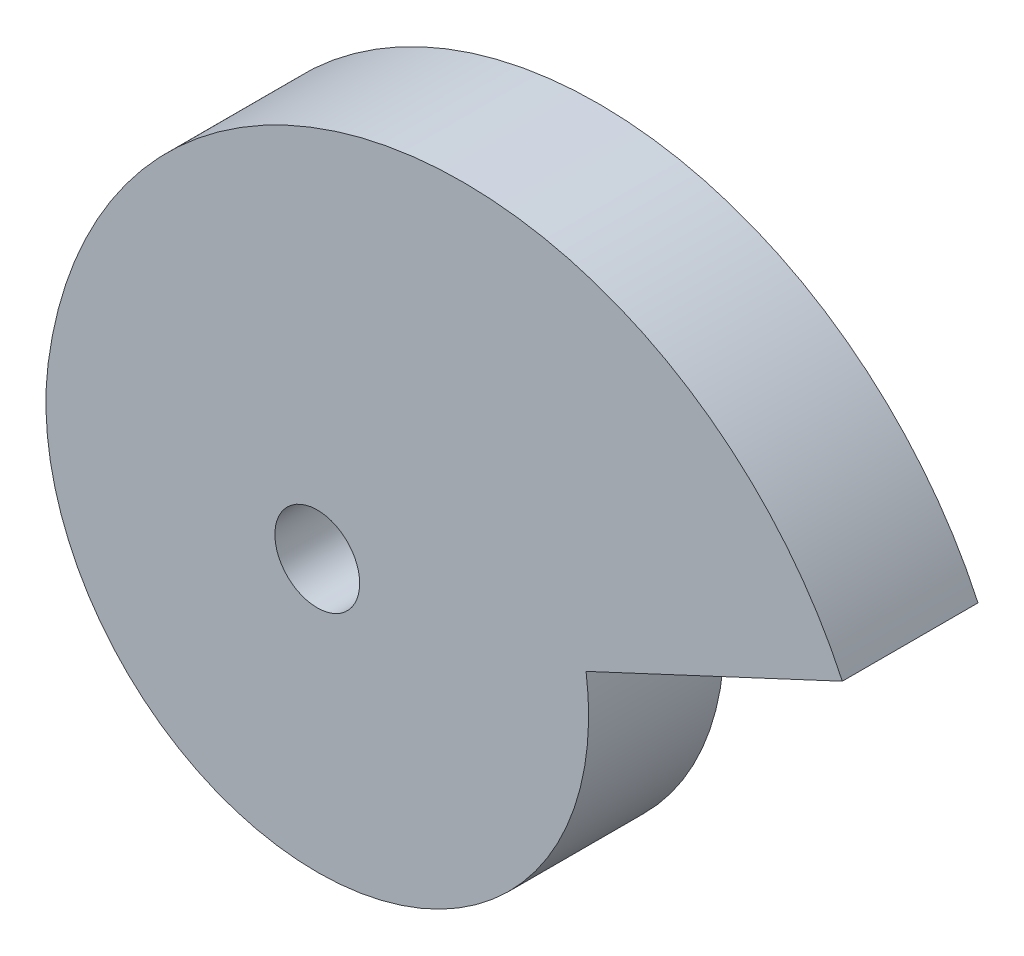
from build123d import *

# Parameters (mm, degrees)
BOSS_EXTRUDE1_DEPTH = 40
SKETCH3_R           = 12.5
CUT_EXTRUDE1_DEPTH  = 40


with BuildPart() as part:
    # Sketch1 → Boss-Extrude1 (new body)
    with BuildSketch(Plane.XY):
        with BuildLine():
            Line((154.789932001, 46.156744782), (79.252857829, 10.908002839))
            ThreePointArc((79.252857829, 10.908002839), (0.316849047, -79.999372539), (-79.336775516, 10.279885735))
            ThreePointArc((-79.336775516, 10.279885735), (24.232279098, 116.279977092), (154.789932001, 46.156744782))
        make_face()
    extrude(amount=BOSS_EXTRUDE1_DEPTH)

    # Sketch3 → Cut-Extrude1 (cut)
    with BuildSketch(Plane.XY.offset(40)):
        Circle(SKETCH3_R)
    extrude(amount=-CUT_EXTRUDE1_DEPTH, mode=Mode.SUBTRACT)


solid = part.part
